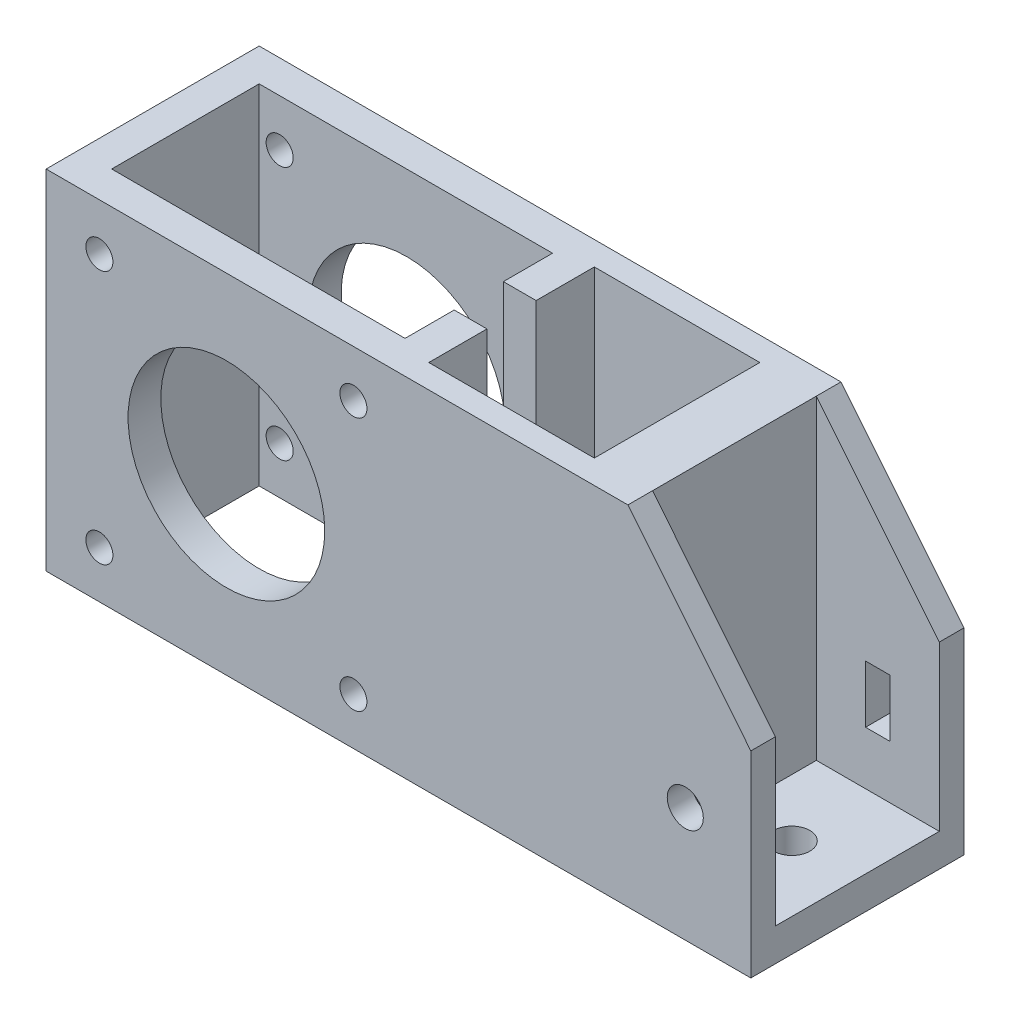
from build123d import *

# Parameters (mm, degrees)
BOSS_EXTRU_1_DEPTH      = 26
ESQUISSE2_R             = 12
ENL_V_MAT_EXTRU_1_DEPTH = 27
ESQUISSE3_W             = 35.8
ESQUISSE3_H             = 18
ESQUISSE3_W_2           = 20.2
ESQUISSE3_H_2           = 20.2
ENL_V_MAT_EXTRU_2_DEPTH = 43.5
ESQUISSE4_W             = 15
ESQUISSE4_H             = 20
ENL_V_MAT_EXTRU_3_DEPTH = 38.5
D_GAGEMENT_M31_D        = 3.3
ENL_V_MAT_EXTRU_4_REACH = 48.2
ESQUISSE7_W             = 6
ESQUISSE7_H             = 16
D_GAGEMENT_M41_D        = 4.4
D_GAGEMENT_M41_DEPTH    = 24
ESQUISSE10_W            = 2.2
ESQUISSE10_H            = 24
ENL_V_MAT_EXTRU_5_REACH = 5
ESQUISSE12_W            = 3
ESQUISSE12_H            = 7


with BuildPart() as part:
    # Esquisse1 → Boss.-Extru.1 (new body)
    with BuildSketch(Plane.XY):
        Polygon((0, 0), (0, -42.5), (86, -42.5), (86, -18.5), (71, 0), align=None)
    extrude(amount=BOSS_EXTRU_1_DEPTH)

    # Esquisse2 → Enlèv. mat.-Extru.1 (cut, through all)
    with BuildSketch(Plane.XY.offset(26)):
        with Locations((22, -21.25)):
            Circle(ESQUISSE2_R)
    extrude(amount=-ENL_V_MAT_EXTRU_1_DEPTH, mode=Mode.SUBTRACT)

    # Esquisse3 → Enlèv. mat.-Extru.2 (cut, through all)
    with BuildSketch(Plane(origin=(0, 0, 0), x_dir=(1, 0, 0), z_dir=(0, 1, 0))):
        with Locations((21.9, -13)):
            Rectangle(ESQUISSE3_W, ESQUISSE3_H)
        with Locations((53.9, -13)):
            Rectangle(ESQUISSE3_W_2, ESQUISSE3_H_2)
    extrude(amount=-ENL_V_MAT_EXTRU_2_DEPTH, mode=Mode.SUBTRACT)

    # Esquisse4 → Enlèv. mat.-Extru.3 (cut)
    with BuildSketch(Plane(origin=(0, 0, 0), x_dir=(1, 0, 0), z_dir=(0, 1, 0))):
        with Locations((78.5, -13)):
            Rectangle(ESQUISSE4_W, ESQUISSE4_H)
    extrude(amount=-ENL_V_MAT_EXTRU_3_DEPTH, mode=Mode.SUBTRACT)

    # Dégagement M31 (through all)
    with Locations(Plane.XY.offset(26)):
        with Locations((22, -21.25), (37.5, -36.75), (6.5, -5.75), (6.5, -36.75), (37.5, -5.75)):
            Hole(D_GAGEMENT_M31_D / 2)

    # Esquisse7 → Enlèv. mat.-Extru.4 (cut, up to next)
    with BuildSketch(Plane.ZY.offset(-39.8), mode=Mode.PRIVATE) as enl_v_mat_extru_4_sk1:
        with Locations((13, -8)):
            Rectangle(ESQUISSE7_W, ESQUISSE7_H)
    enl_v_mat_extru_4_tool1 = extrude(enl_v_mat_extru_4_sk1.sketch, amount=-ENL_V_MAT_EXTRU_4_REACH, mode=Mode.PRIVATE) & part.part
    add(enl_v_mat_extru_4_tool1.solids().sort_by_distance((39.8, -8, 13))[0], mode=Mode.SUBTRACT)
    # Esquisse7 → Enlèv. mat.-Extru.4 (cut, up to next)
    with BuildSketch(Plane.ZY.offset(-39.8), mode=Mode.PRIVATE) as enl_v_mat_extru_4_sk2:
        with Locations((13, -34.5)):
            Rectangle(ESQUISSE7_W, ESQUISSE7_H)
    enl_v_mat_extru_4_tool2 = extrude(enl_v_mat_extru_4_sk2.sketch, amount=-ENL_V_MAT_EXTRU_4_REACH, mode=Mode.PRIVATE) & part.part
    add(enl_v_mat_extru_4_tool2.solids().sort_by_distance((39.8, -34.5, 13))[0], mode=Mode.SUBTRACT)

    # Dégagement M41
    with Locations(Plane(origin=(0, -38.5, 0), x_dir=(1, 0, 0), z_dir=(0, 1, 0))):
        with Locations((78, -13)):
            Hole(D_GAGEMENT_M41_D / 2, depth=D_GAGEMENT_M41_DEPTH)

    # Esquisse10 → Dégagement M42 (revolve, cut)
    with BuildSketch(Plane(origin=(78, -28.5, 23), x_dir=(0, 1, 0), z_dir=(1, 0, 0))):
        with Locations((1.1, 12)):
            Rectangle(ESQUISSE10_W, ESQUISSE10_H)
    revolve(axis=Axis((78, -28.5, 16.65), (0, 0, 1)), mode=Mode.SUBTRACT)

    # Esquisse12 → Enlèv. mat.-Extru.5 (cut, up to next)
    with BuildSketch(Plane.XY.offset(3), mode=Mode.PRIVATE) as enl_v_mat_extru_5_sk1:
        with Locations((78.5, -28.5)):
            Rectangle(ESQUISSE12_W, ESQUISSE12_H)
    enl_v_mat_extru_5_tool1 = extrude(enl_v_mat_extru_5_sk1.sketch, amount=-ENL_V_MAT_EXTRU_5_REACH, mode=Mode.PRIVATE) & part.part
    add(enl_v_mat_extru_5_tool1.solids().sort_by_distance((78.5, -28.5, 3))[0], mode=Mode.SUBTRACT)


solid = part.part
